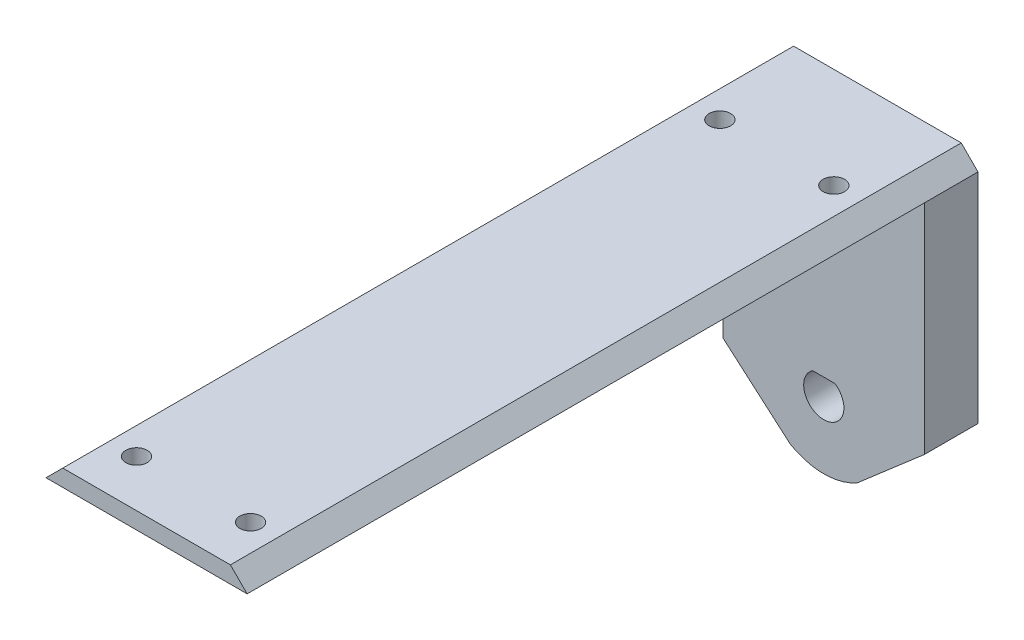
from build123d import *

# Parameters (mm, degrees)
BOSS_EXTRUDE1_DEPTH  = 8
BOSS_EXTRUDE3_DEPTH  = 109
M3_CLEARANCE_SLOT1_D = 3.2


with BuildPart() as part:
    # Sketch1 → Boss-Extrude1 (new body)
    with BuildSketch(Plane.XY):
        with BuildLine():
            Line((15, 25.5), (-15, 25.5))
            Line((-15, 25.5), (-15, -7))
            Line((-15, -7), (-5, -15.660254038))
            ThreePointArc((-5, -15.660254038), (0, -17), (5, -15.660254038))
            Line((5, -15.660254038), (15, -7))
            Line((15, -7), (15, 25.5))
        make_face()
        with BuildLine():
            Line((1.658312395, -4.5), (-1.658312395, -4.5))
            ThreePointArc((-1.658312395, -4.5), (0, -10), (1.658312395, -4.5))
        make_face(mode=Mode.SUBTRACT)
    extrude(amount=BOSS_EXTRUDE1_DEPTH)

    # Sketch1_5 → Boss-Extrude3 (add)
    with BuildSketch(Plane.XY):
        Polygon((-12.5, 28), (12.5, 28), (15, 25.5), (-15, 25.5), align=None)
    extrude(amount=BOSS_EXTRUDE3_DEPTH)

    # M3 Clearance Slot1 (through all)
    with Locations(Plane(origin=(0, 28, 0), x_dir=(1, 0, 0), z_dir=(0, 1, 0))):
        with Locations((-8.5, -15), (8.5, -15), (-8.5, -102), (8.5, -102)):
            Hole(M3_CLEARANCE_SLOT1_D / 2)


solid = part.part
